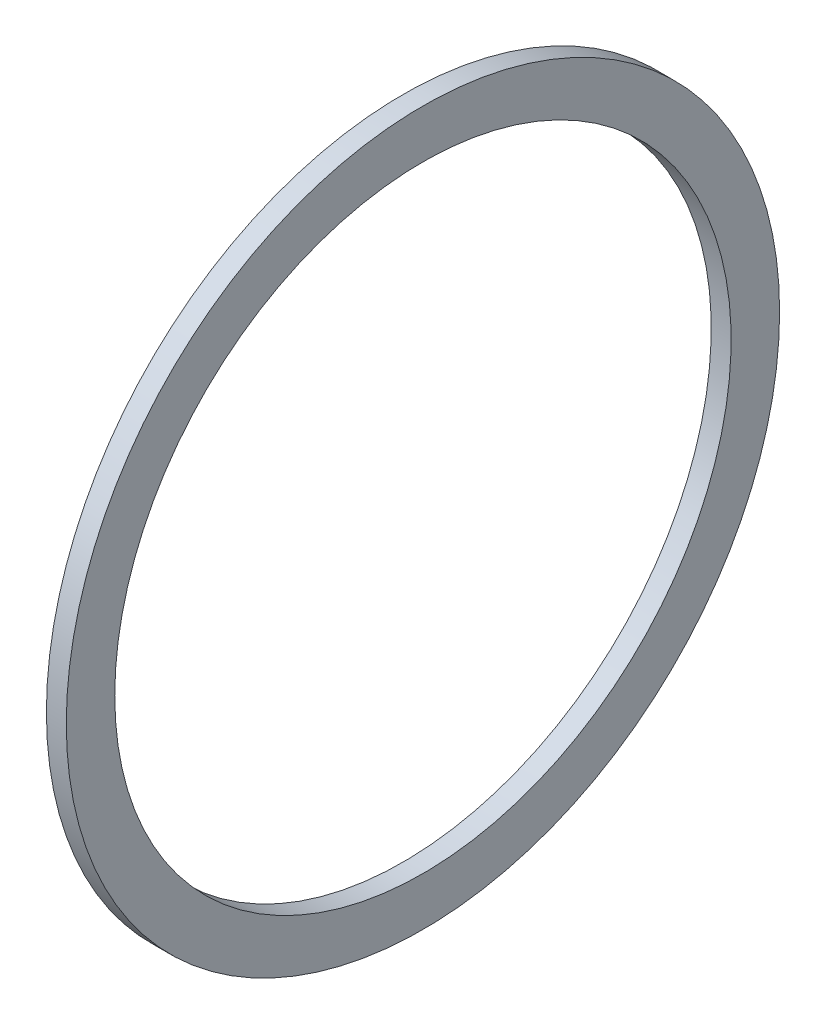
from build123d import *

# Parameters (mm, degrees)
SKETCH1_W = 2.032
SKETCH1_H = 4.953


with BuildPart() as part:
    # Sketch1 → Revolve1 (revolve)
    with BuildSketch(Plane.XY, mode=Mode.PRIVATE) as revolve1_sk:
        with Locations((1.016, -33.9725)):
            Rectangle(SKETCH1_W, SKETCH1_H)
    revolve(revolve1_sk.sketch.rotate(Axis((-43.716580756, 0, 0), (1, 0, 0)), 270), axis=Axis((-43.716580756, 0, 0), (1, 0, 0)))  # turned: the seam where the file's is


solid = part.part
